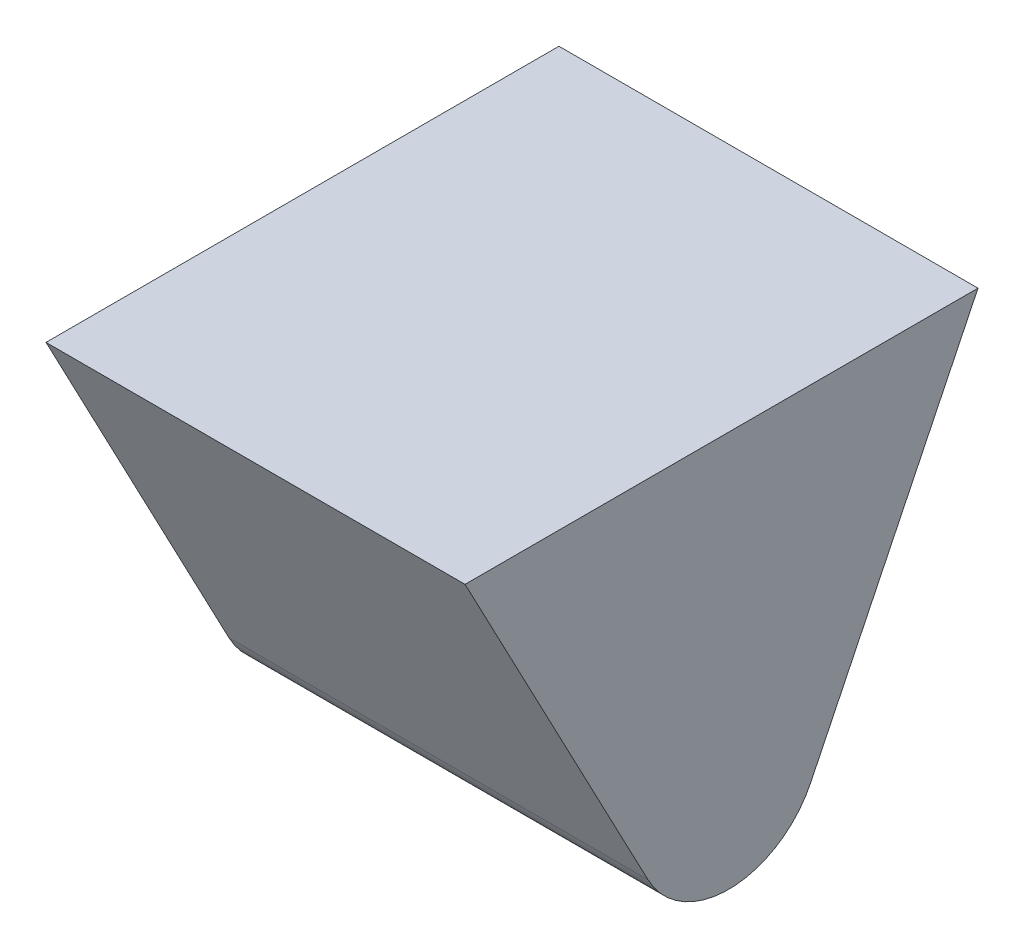
from build123d import *

# Parameters (mm, degrees)
BOSS_EXTRUDE2_DEPTH = 5.842
FILLET2_R           = 1.27


with BuildPart() as part:
    # Sketch1 → Boss-Extrude2 (new body)
    with BuildSketch(Plane(origin=(0, 0, 0), x_dir=(0, 0, -1), z_dir=(1, 0, 0))):
        Polygon((-9.860284519, 7.064140975), (-2.70926767, 7.064140975), (-6.139028999, 0), align=None)
    extrude(amount=BOSS_EXTRUDE2_DEPTH)

    # Fillet2
    fillet2_edges = [part.edges().sort_by_distance(p)[0] for p in [
        (2.921, 0, 6.139028999),
    ]]
    fillet(fillet2_edges, radius=FILLET2_R)


solid = part.part
